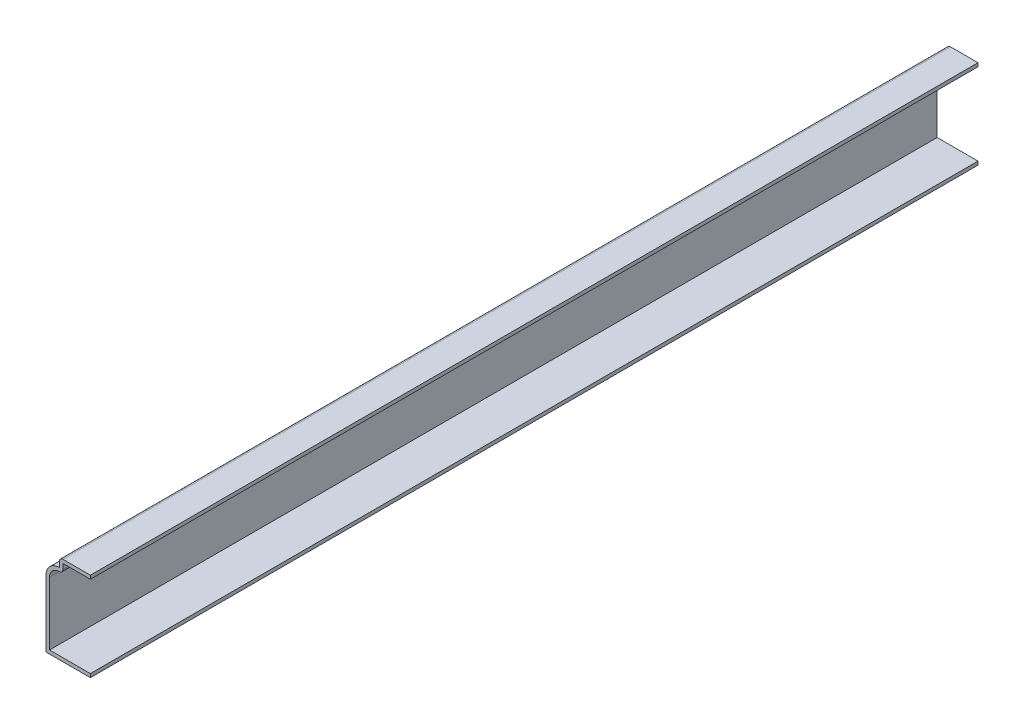
from build123d import *

# Parameters (mm, degrees)
EXTRUDE_THIN1_DEPTH = 317.5
FILLET1_R           = 1.27


with BuildPart() as part:
    # Sketch1 → Extrude-Thin1 (new body)
    with BuildSketch(Plane.XY):
        with BuildLine():
            Line((0, 0), (-15.875, 0))
            Line((-15.875, 0), (-15.875, 23.8125))
            ThreePointArc((-15.875, 23.8125), (-14.480096045, 27.180096045), (-11.1125, 28.575))
            Line((-11.1125, 28.575), (-11.1125, 31.75))
            Line((-11.1125, 31.75), (0, 31.75))
            Line((0, 31.75), (0, 30.48))
            Line((0, 30.48), (-9.8425, 30.48))
            Line((-9.8425, 30.48), (-9.8425, 27.065906868))
            ThreePointArc((-9.8425, 27.065906868), (-13.082535691, 26.696336962), (-14.605, 23.8125))
            Line((-14.605, 23.8125), (-14.605, 1.27))
            Line((-14.605, 1.27), (0, 1.27))
            Line((0, 1.27), (0, 0))
        make_face()
    extrude(amount=-EXTRUDE_THIN1_DEPTH)

    # Fillet1
    fillet1_edges = [part.edges().sort_by_distance(p)[0] for p in [
        (-9.8425, 27.065906868, -158.75),
        (-11.1125, 31.75, -158.75),
    ]]
    fillet(fillet1_edges, radius=FILLET1_R)


solid = part.part
